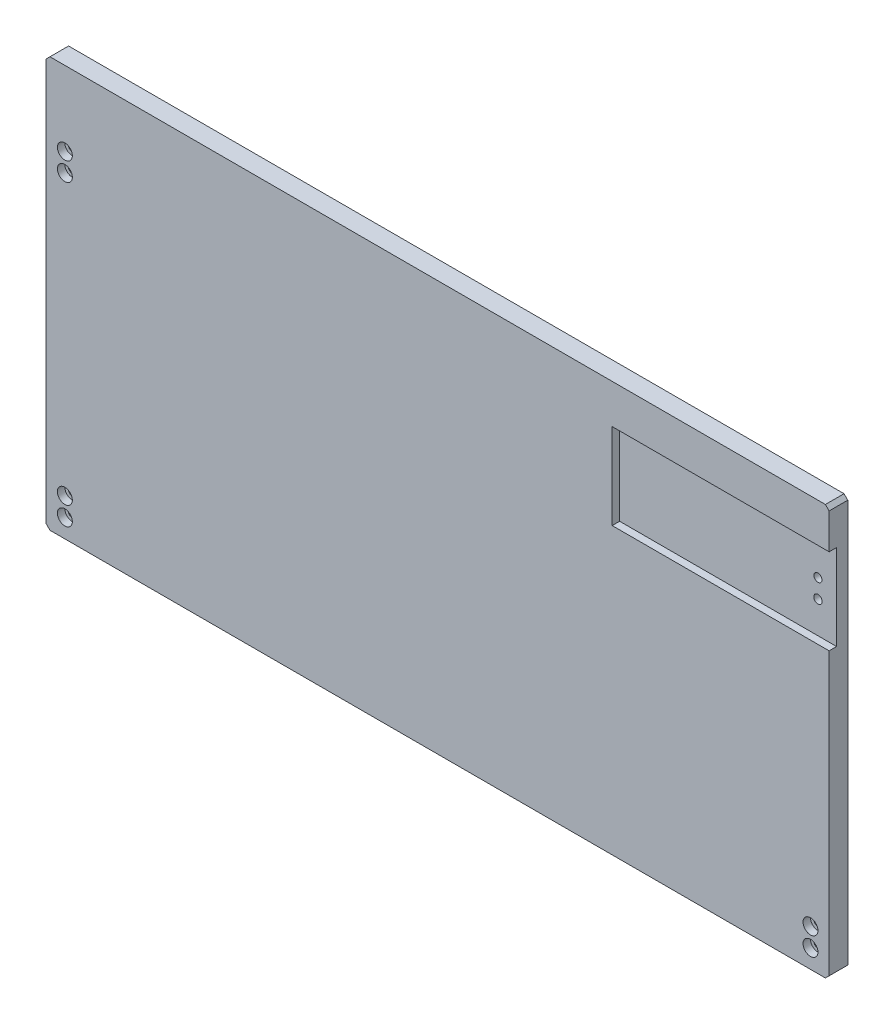
from build123d import *

# Parameters (mm, degrees)
SKETCH1_W           = 420
SKETCH1_H           = 220
BOSS_EXTRUDE1_DEPTH = 10
SKETCH2_R           = 2.25
CUT_EXTRUDE1_DEPTH  = 10
SKETCH3_R           = 4
CUT_EXTRUDE2_DEPTH  = 4
CHAMFER1_SIZE       = 2
SKETCH5_W           = 4
SKETCH5_H           = 46
CUT_EXTRUDE3_DEPTH  = 116.38
SKETCH7_R           = 2.15
CUT_EXTRUDE4_DEPTH  = 11
SKETCH8_R           = 4
CUT_EXTRUDE5_DEPTH  = 4


with BuildPart() as part:
    # Sketch1 → Boss-Extrude1 (new body)
    with BuildSketch(Plane.XY):
        Rectangle(SKETCH1_W, SKETCH1_H)
    extrude(amount=BOSS_EXTRUDE1_DEPTH)

    # Sketch2 → Cut-Extrude1 (cut)
    with BuildSketch(Plane.XY.offset(10)):
        with Locations((-200, 60)):
            Circle(SKETCH2_R)
        with Locations((200, 60)):
            Circle(SKETCH2_R)
        with Locations((200, -100)):
            Circle(SKETCH2_R)
        with Locations((-200, -100)):
            Circle(SKETCH2_R)
    extrude(amount=-CUT_EXTRUDE1_DEPTH, mode=Mode.SUBTRACT)

    # Sketch3 → Cut-Extrude2 (cut)
    with BuildSketch(Plane.XY.offset(10)):
        with Locations((-200, 60)):
            Circle(SKETCH3_R)
        with Locations((-200, -100)):
            Circle(SKETCH3_R)
        with Locations((200, 60)):
            Circle(SKETCH3_R)
        with Locations((200, -100)):
            Circle(SKETCH3_R)
    extrude(amount=-CUT_EXTRUDE2_DEPTH, mode=Mode.SUBTRACT)

    # Chamfer1
    chamfer1_edges = [part.edges().sort_by_distance(p)[0] for p in [
        (210, -110, 5),
        (-210, -110, 5),
        (-210, 110, 5),
        (210, 110, 5),
    ]]
    chamfer(chamfer1_edges, length=CHAMFER1_SIZE)

    # Sketch5 → Cut-Extrude3 (cut)
    with BuildSketch(Plane(origin=(210, 0, 0), x_dir=(0, 0, -1), z_dir=(1, 0, 0))):
        with Locations((-8, 66)):
            Rectangle(SKETCH5_W, SKETCH5_H)
    extrude(amount=-CUT_EXTRUDE3_DEPTH, mode=Mode.SUBTRACT)

    # Sketch7 → Cut-Extrude4 (cut, through all)
    with BuildSketch(Plane.XY.offset(10)):
        with Locations((200, -90)):
            Circle(SKETCH7_R)
        with Locations((200, 70)):
            Circle(SKETCH7_R)
        with Locations((-200, -90)):
            Circle(SKETCH7_R)
        with Locations((-200, 70)):
            Circle(SKETCH7_R)
    extrude(amount=-CUT_EXTRUDE4_DEPTH, mode=Mode.SUBTRACT)

    # Sketch8 → Cut-Extrude5 (cut)
    with BuildSketch(Plane.XY.offset(10)):
        with Locations((-200, 70)):
            Circle(SKETCH8_R)
        with Locations((-200, -90)):
            Circle(SKETCH8_R)
        with Locations((200, -90)):
            Circle(SKETCH8_R)
    extrude(amount=-CUT_EXTRUDE5_DEPTH, mode=Mode.SUBTRACT)


solid = part.part
